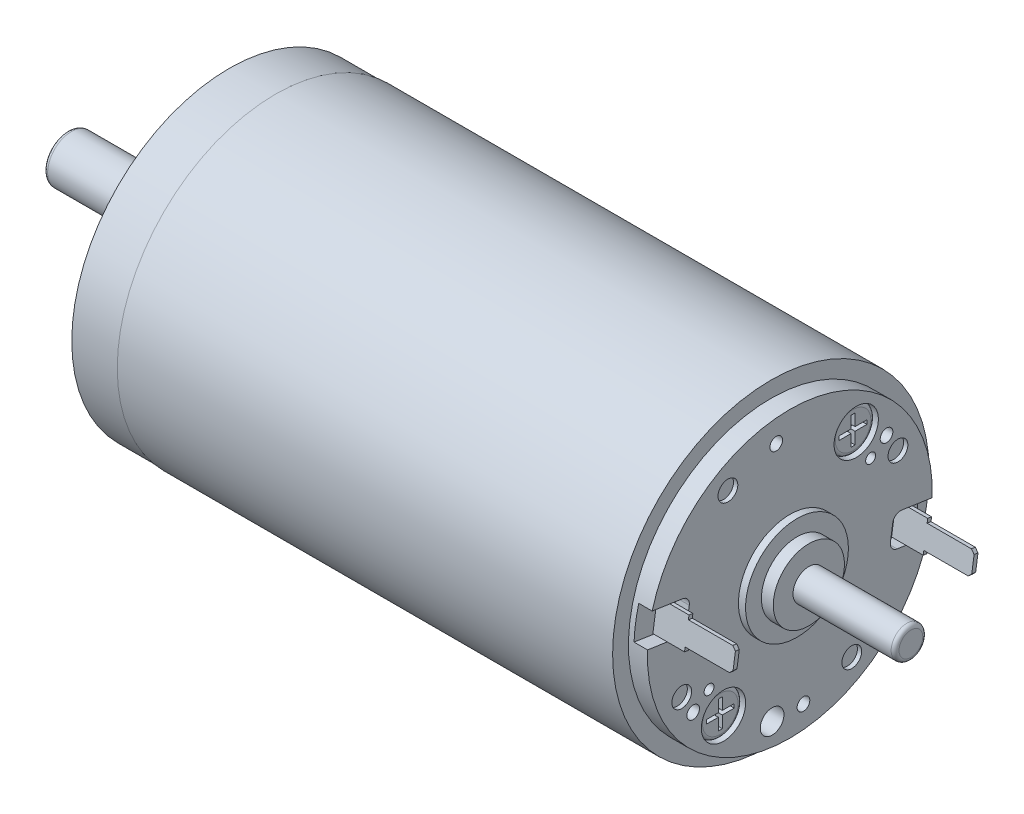
from build123d import *

# Parameters (mm, degrees)
IZIM1_W                      = 62.6
IZIM1_H                      = 20
IZIM2_R                      = 18
Y_KSEKLIK_EKSTR_ZYON1_DEPTH  = 2.4
KES_EKSTR_ZYON1_DEPTH        = 1.7
Y_KSEKLIK_EKSTR_ZYON2_DEPTH  = 10
IZIM5_W                      = 6
IZIM5_H                      = 0.5
KES_EKSTR_ZYON2_DEPTH        = 8.73650549
IZIM6_W                      = 6
IZIM6_H                      = 0.5
KES_EKSTR_ZYON3_DEPTH        = 8.73650549
KES_EKSTR_ZYON4_DEPTH        = 1.7
Y_KSEKLIK_EKSTR_ZYON3_DEPTH  = 10
IZIM9_W                      = 6
IZIM9_H                      = 0.5
KES_EKSTR_ZYON5_DEPTH        = 8.73650549
IZIM10_W                     = 6
IZIM10_H                     = 0.5
KES_EKSTR_ZYON6_DEPTH        = 8.73650549
IZIM11_R                     = 19.9
Y_KSEKLIK_EKSTR_ZYON4_DEPTH  = 5.85
IZIM12_R                     = 18.5
Y_KSEKLIK_EKSTR_ZYON5_DEPTH  = 0.15
IZIM13_R                     = 8
Y_KSEKLIK_EKSTR_ZYON6_DEPTH  = 1.4
IZIM14_R                     = 4.5
Y_KSEKLIK_EKSTR_ZYON7_DEPTH  = 2.15
IZIM15_R                     = 3
Y_KSEKLIK_EKSTR_ZYON8_DEPTH  = 16.75
IZIM16_R                     = 6.5
Y_KSEKLIK_EKSTR_ZYON9_DEPTH  = 0.9
IZIM17_R                     = 4.5
Y_KSEKLIK_EKSTR_ZYON10_DEPTH = 1.5
IZIM18_R                     = 2
Y_KSEKLIK_EKSTR_ZYON11_DEPTH = 12.9
F_5_6_5_6_AP_DELIK1_D        = 5.6
F_5_6_5_6_AP_DELIK1_DEPTH    = 2.4
IZIM21_R                     = 2.75
Y_KSEKLIK_EKSTR_ZYON12_DEPTH = 2
KES_EKSTR_ZYON7_DEPTH        = 0.86
F_5_6_5_6_AP_DELIK2_D        = 5.6
F_5_6_5_6_AP_DELIK2_DEPTH    = 2.4
IZIM25_R                     = 2.75
Y_KSEKLIK_EKSTR_ZYON13_DEPTH = 2
KES_EKSTR_ZYON8_DEPTH        = 0.86
F_3_0_3_AP_DELIK1_D          = 3
F_3_0_3_AP_DELIK1_DEPTH      = 3.4
F_2_5_2_5_AP_DELIK1_D        = 2.5
F_2_5_2_5_AP_DELIK1_DEPTH    = 0.54
F_1_25_1_25_AP_DELIK1_D      = 1.25
F_1_25_1_25_AP_DELIK1_DEPTH  = 3.75
F_1_25_1_25_AP_DELIK1_TIP    = 0.360843918
F_1_6_1_6_AP_DELIK1_D        = 1.6
F_1_6_1_6_AP_DELIK1_DEPTH    = 4.8
F_1_6_1_6_AP_DELIK1_TIP      = 0.461880215
F_2_5_2_5_AP_DELIK2_D        = 2.5
F_2_5_2_5_AP_DELIK2_DEPTH    = 7.5
F_2_5_2_5_AP_DELIK2_TIP      = 0.721687836
F_2_8_2_8_AP_DELIK1_D        = 2.8
F_2_8_2_8_AP_DELIK1_DEPTH    = 1.2
F_2_8_2_8_AP_DELIK1_TIP      = 0.808290377
PAH1_SIZE                    = 0.4
RADYUS1_R                    = 0.5
RADYUS2_R                    = 1


with BuildPart() as part:
    # Çizim1 → Döndür1 (revolve)
    with BuildSketch(Plane.XY):
        with Locations((37.3, 10)):
            Rectangle(IZIM1_W, IZIM1_H)
    revolve(axis=Axis((6, 0, 0), (1, 0, 0)))

    # Çizim2 → Yükseklik-Ekstrüzyon1 (add)
    with BuildSketch(Plane(origin=(68.6, 0, 0), x_dir=(0, 0, -1), z_dir=(1, 0, 0))):
        Circle(IZIM2_R)
    extrude(amount=Y_KSEKLIK_EKSTR_ZYON1_DEPTH)

    # Çizim3 → Kes-Ekstrüzyon1 (cut)
    with BuildSketch(Plane(origin=(71, 0, 0), x_dir=(0, 0, -1), z_dir=(1, 0, 0))):
        with BuildLine():
            Line((17.987672433, -0.666063401), (13.152825046, 0.056509382))
            Line((13.152825046, 0.056509382), (12.561587401, -3.899554071))
            Line((12.561587401, -3.899554071), (17.396434788, -4.622126855))
            ThreePointArc((17.396434788, -4.622126855), (17.802285541, -2.6605694), (17.987672433, -0.666063401))
        make_face()
    extrude(amount=-KES_EKSTR_ZYON1_DEPTH, mode=Mode.SUBTRACT)

    # Çizim4 → Yükseklik-Ekstrüzyon2 (add)
    with BuildSketch(Plane(origin=(69.3, 0, 0), x_dir=(0, 0, -1), z_dir=(1, 0, 0))):
        Polygon((15.048908001, -4.170176013), (14.554400069, -4.096271307), (15.116075832, -0.338011027), (15.610583763, -0.411915732), align=None)
    extrude(amount=Y_KSEKLIK_EKSTR_ZYON2_DEPTH)

    # Çizim5 → Kes-Ekstrüzyon2 (cut, through all)
    with BuildSketch(Plane(origin=(0, -2.217141167, -14.83523795), x_dir=(1, 0, 0), z_dir=(0, 0.147809411, 0.989015863))):
        with Locations((76.3, 1.65)):
            Rectangle(IZIM5_W, IZIM5_H)
    extrude(amount=-KES_EKSTR_ZYON2_DEPTH, mode=Mode.SUBTRACT)

    # Çizim6 → Kes-Ekstrüzyon3 (cut, through all)
    with BuildSketch(Plane(origin=(0, -2.217141167, -14.83523795), x_dir=(1, 0, 0), z_dir=(0, 0.147809411, 0.989015863))):
        with Locations((76.3, -1.65)):
            Rectangle(IZIM6_W, IZIM6_H)
    extrude(amount=-KES_EKSTR_ZYON3_DEPTH, mode=Mode.SUBTRACT)

    # Çizim7 → Kes-Ekstrüzyon4 (cut)
    with BuildSketch(Plane(origin=(71, 0, 0), x_dir=(0, 0, -1), z_dir=(1, 0, 0))):
        with BuildLine():
            Line((-17.987672433, 0.666063401), (-13.152825046, -0.056509382))
            Line((-13.152825046, -0.056509382), (-12.561587401, 3.899554071))
            Line((-12.561587401, 3.899554071), (-17.396434788, 4.622126855))
            ThreePointArc((-17.396434788, 4.622126855), (-17.802285541, 2.6605694), (-17.987672433, 0.666063401))
        make_face()
    extrude(amount=-KES_EKSTR_ZYON4_DEPTH, mode=Mode.SUBTRACT)

    # Çizim8 → Yükseklik-Ekstrüzyon3 (add)
    with BuildSketch(Plane(origin=(69.3, 0, 0), x_dir=(0, 0, -1), z_dir=(1, 0, 0))):
        Polygon((-15.048908001, 4.170176013), (-14.554400069, 4.096271307), (-15.116075832, 0.338011027), (-15.610583763, 0.411915732), align=None)
    extrude(amount=Y_KSEKLIK_EKSTR_ZYON3_DEPTH)

    # Çizim9 → Kes-Ekstrüzyon5 (cut, through all)
    with BuildSketch(Plane(origin=(0, 2.217141167, 14.83523795), x_dir=(-1, 0, 0), z_dir=(0, -0.147809411, -0.989015863))):
        with Locations((-76.3, -1.65)):
            Rectangle(IZIM9_W, IZIM9_H)
    extrude(amount=-KES_EKSTR_ZYON5_DEPTH, mode=Mode.SUBTRACT)

    # Çizim10 → Kes-Ekstrüzyon6 (cut, through all)
    with BuildSketch(Plane(origin=(0, 2.217141167, 14.83523795), x_dir=(-1, 0, 0), z_dir=(0, -0.147809411, -0.989015863))):
        with Locations((-76.3, 1.65)):
            Rectangle(IZIM10_W, IZIM10_H)
    extrude(amount=-KES_EKSTR_ZYON6_DEPTH, mode=Mode.SUBTRACT)

    # Çizim11 → Yükseklik-Ekstrüzyon4 (add)
    with BuildSketch(Plane.ZY.offset(-6)):
        Circle(IZIM11_R)
    extrude(amount=Y_KSEKLIK_EKSTR_ZYON4_DEPTH)

    # Çizim12 → Yükseklik-Ekstrüzyon5 (add)
    with BuildSketch(Plane.ZY.offset(-0.15)):
        Circle(IZIM12_R)
    extrude(amount=Y_KSEKLIK_EKSTR_ZYON5_DEPTH)

    # Çizim13 → Yükseklik-Ekstrüzyon6 (add)
    with BuildSketch(Plane.ZY):
        Circle(IZIM13_R)
    extrude(amount=Y_KSEKLIK_EKSTR_ZYON6_DEPTH)

    # Çizim14 → Yükseklik-Ekstrüzyon7 (add)
    with BuildSketch(Plane.ZY.offset(1.4)):
        Circle(IZIM14_R)
    extrude(amount=Y_KSEKLIK_EKSTR_ZYON7_DEPTH)

    # Çizim15 → Yükseklik-Ekstrüzyon8 (add)
    with BuildSketch(Plane.ZY.offset(3.55)):
        Circle(IZIM15_R)
    extrude(amount=Y_KSEKLIK_EKSTR_ZYON8_DEPTH)

    # Çizim16 → Yükseklik-Ekstrüzyon9 (add)
    with BuildSketch(Plane(origin=(71, 0, 0), x_dir=(0, 0, -1), z_dir=(1, 0, 0))):
        Circle(IZIM16_R)
    extrude(amount=Y_KSEKLIK_EKSTR_ZYON9_DEPTH)

    # Çizim17 → Yükseklik-Ekstrüzyon10 (add)
    with BuildSketch(Plane(origin=(71.9, 0, 0), x_dir=(0, 0, -1), z_dir=(1, 0, 0))):
        Circle(IZIM17_R)
    extrude(amount=Y_KSEKLIK_EKSTR_ZYON10_DEPTH)

    # Çizim18 → Yükseklik-Ekstrüzyon11 (add)
    with BuildSketch(Plane(origin=(73.4, 0, 0), x_dir=(0, 0, -1), z_dir=(1, 0, 0))):
        Circle(IZIM18_R)
    extrude(amount=Y_KSEKLIK_EKSTR_ZYON11_DEPTH)

    # Ø5.6 (5.6) Çap Delik1
    with Locations(Plane(origin=(71, 0, 0), x_dir=(0, 0, -1), z_dir=(1, 0, 0))):
        with Locations((8.387001293, 11.334381735)):
            Hole(F_5_6_5_6_AP_DELIK1_D / 2, depth=F_5_6_5_6_AP_DELIK1_DEPTH)

    # Çizim21 → Yükseklik-Ekstrüzyon12 (add)
    with BuildSketch(Plane(origin=(68.6, 0, 0), x_dir=(0, 0, -1), z_dir=(1, 0, 0))):
        with Locations((8.387001293, 11.334381735)):
            Circle(IZIM21_R)
    extrude(amount=Y_KSEKLIK_EKSTR_ZYON12_DEPTH)

    # Çizim22 → Kes-Ekstrüzyon7 (cut)
    with BuildSketch(Plane(origin=(70.6, 0, 0), x_dir=(0, 0, -1), z_dir=(1, 0, 0))):
        Polygon((8.137001293, 13.084381735), (8.137001293, 11.584381735), (6.637001293, 11.584381735), (6.637001293, 11.084381735), (8.137001293, 11.084381735), (8.137001293, 9.584381735), (8.637001293, 9.584381735), (8.637001293, 11.084381735), (10.137001293, 11.084381735), (10.137001293, 11.584381735), (8.637001293, 11.584381735), (8.637001293, 13.084381735), align=None)
    extrude(amount=-KES_EKSTR_ZYON7_DEPTH, mode=Mode.SUBTRACT)

    # Ø5.6 (5.6) Çap Delik2
    with Locations(Plane(origin=(71, 0, 0), x_dir=(0, 0, -1), z_dir=(1, 0, 0))):
        with Locations((-8.387001293, -11.334381735)):
            Hole(F_5_6_5_6_AP_DELIK2_D / 2, depth=F_5_6_5_6_AP_DELIK2_DEPTH)

    # Çizim25 → Yükseklik-Ekstrüzyon13 (add)
    with BuildSketch(Plane(origin=(68.6, 0, 0), x_dir=(0, 0, -1), z_dir=(1, 0, 0))):
        with Locations((-8.387001293, -11.334381735)):
            Circle(IZIM25_R)
    extrude(amount=Y_KSEKLIK_EKSTR_ZYON13_DEPTH)

    # Çizim26 → Kes-Ekstrüzyon8 (cut)
    with BuildSketch(Plane(origin=(70.6, 0, 0), x_dir=(0, 0, -1), z_dir=(1, 0, 0))):
        Polygon((-8.637001293, -9.584381735), (-8.637001293, -11.084381735), (-10.137001293, -11.084381735), (-10.137001293, -11.584381735), (-8.637001293, -11.584381735), (-8.637001293, -13.084381735), (-8.137001293, -13.084381735), (-8.137001293, -11.584381735), (-6.637001293, -11.584381735), (-6.637001293, -11.084381735), (-8.137001293, -11.084381735), (-8.137001293, -9.584381735), align=None)
    extrude(amount=-KES_EKSTR_ZYON8_DEPTH, mode=Mode.SUBTRACT)

    # Ø3.0 (3) Çap Delik1
    with Locations(Plane(origin=(71, 0, 0), x_dir=(0, 0, -1), z_dir=(1, 0, 0))):
        with Locations((-2.242983813, -15.034793767)):
            Hole(F_3_0_3_AP_DELIK1_D / 2, depth=F_3_0_3_AP_DELIK1_DEPTH)

    # Ø2.5 (2.5) Çap Delik1
    with Locations(Plane(origin=(71, 0, 0), x_dir=(0, 0, -1), z_dir=(1, 0, 0))):
        with Locations((7.828578739, -13.028942971), (-7.828578739, 13.028942971), (13.661669504, 6.663241431), (-13.661669504, -6.663241431)):
            Hole(F_2_5_2_5_AP_DELIK1_D / 2, depth=F_2_5_2_5_AP_DELIK1_DEPTH)

    # Ø1.25 (1.25) Çap Delik1
    with Locations(Plane(origin=(71, 0, 0), x_dir=(0, 0, -1), z_dir=(1, 0, 0))):
        with Locations((10.20898213, 7.554249392), (-10.20898213, -7.554249392)):
            Hole(F_1_25_1_25_AP_DELIK1_D / 2, depth=F_1_25_1_25_AP_DELIK1_DEPTH)
            with Locations((0, 0, -(F_1_25_1_25_AP_DELIK1_DEPTH + F_1_25_1_25_AP_DELIK1_TIP / 2))):  # 120° drill point
                Cone(0, F_1_25_1_25_AP_DELIK1_D / 2, F_1_25_1_25_AP_DELIK1_TIP, mode=Mode.SUBTRACT)

    # Ø1.6 (1.6) Çap Delik1
    with Locations(Plane(origin=(71, 0, 0), x_dir=(0, 0, -1), z_dir=(1, 0, 0))):
        with Locations((-1.720688849, 15.102292206), (1.720688849, -15.102292206), (12.218624281, 9.041306359), (-12.218624281, -9.041306359)):
            Hole(F_1_6_1_6_AP_DELIK1_D / 2, depth=F_1_6_1_6_AP_DELIK1_DEPTH)
            with Locations((0, 0, -(F_1_6_1_6_AP_DELIK1_DEPTH + F_1_6_1_6_AP_DELIK1_TIP / 2))):  # 120° drill point
                Cone(0, F_1_6_1_6_AP_DELIK1_D / 2, F_1_6_1_6_AP_DELIK1_TIP, mode=Mode.SUBTRACT)

    # Ø2.5 (2.5) Çap Delik2
    with Locations(Plane.ZY):
        with Locations((0, 11), (9.526279442, 5.5), (9.526279442, -5.5), (0, -11), (-9.526279442, -5.5), (-9.526279442, 5.5)):
            Hole(F_2_5_2_5_AP_DELIK2_D / 2, depth=F_2_5_2_5_AP_DELIK2_DEPTH)
            with Locations((0, 0, -(F_2_5_2_5_AP_DELIK2_DEPTH + F_2_5_2_5_AP_DELIK2_TIP / 2))):  # 120° drill point
                Cone(0, F_2_5_2_5_AP_DELIK2_D / 2, F_2_5_2_5_AP_DELIK2_TIP, mode=Mode.SUBTRACT)

    # Ø2.8 (2.8) Çap Delik1
    with Locations(Plane.ZY):
        with Locations((0, 15)):
            Hole(F_2_8_2_8_AP_DELIK1_D / 2, depth=F_2_8_2_8_AP_DELIK1_DEPTH)
            with Locations((0, 0, -(F_2_8_2_8_AP_DELIK1_DEPTH + F_2_8_2_8_AP_DELIK1_TIP / 2))):  # 120° drill point
                Cone(0, F_2_8_2_8_AP_DELIK1_D / 2, F_2_8_2_8_AP_DELIK1_TIP, mode=Mode.SUBTRACT)

    # Pah1
    pah1_edges = [part.edges().sort_by_distance(p)[0] for p in [
        (79.3, 0.869471311, 15.289425092),
        (79.3, 3.638715728, 14.875558741),
        (79.3, -0.869471311, -15.289425092),
        (79.3, -3.638715728, -14.875558741),
    ]]
    chamfer(pah1_edges, length=PAH1_SIZE)

    # Radyus1
    radyus1_edges = [part.edges().sort_by_distance(p)[0] for p in [
        (-20.3, 0, -3),
        (86.3, 0, 2),
        (70.6, 11.334381735, -5.637001293),
        (70.6, -11.334381735, 11.137001293),
    ]]
    fillet(radyus1_edges, radius=RADYUS1_R)

    # Radyus2
    radyus2_edges = [part.edges().sort_by_distance(p)[0] for p in [
        (70.15, -3.899554071, -12.561587401),
        (70.15, 0.056509382, -13.152825046),
        (70.15, 3.899554071, 12.561587401),
        (70.15, -0.056509382, 13.152825046),
    ]]
    fillet(radyus2_edges, radius=RADYUS2_R)


solid = part.part
